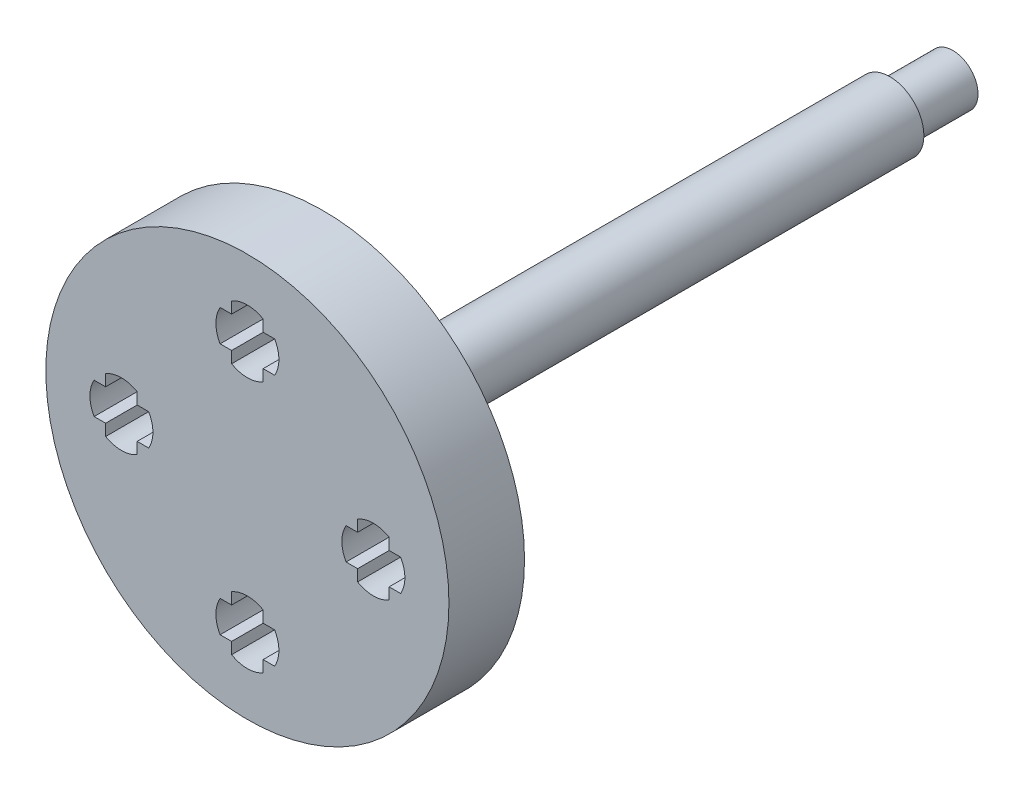
from build123d import *

# Parameters (mm, degrees)
CROQUIS2_R              = 16
SALIENTE_EXTRUIR1_DEPTH = 6
CROQUIS3_R              = 2.7
SALIENTE_EXTRUIR2_DEPTH = 50
CROQUIS4_R              = 2.7
CROQUIS4_R_2            = 2
CORTAR_EXTRUIR1_DEPTH   = 5


with BuildPart() as part:
    # Croquis2 → Saliente-Extruir1 (new body)
    with BuildSketch(Plane.XY):
        Circle(CROQUIS2_R)
        with BuildLine():
            Line((1.25, 12.165063509), (1.25, 11.25))
            Line((1.25, 11.25), (2.165063509, 11.25))
            ThreePointArc((2.165063509, 11.25), (2.414814566, 10.647047613), (2.5, 10))
            ThreePointArc((2.5, 10), (2.414814566, 9.352952387), (2.165063509, 8.75))
            Line((2.165063509, 8.75), (1.25, 8.75))
            Line((1.25, 8.75), (1.25, 7.834936491))
            ThreePointArc((1.25, 7.834936491), (0.647047613, 7.585185434), (0, 7.5))
            ThreePointArc((0, 7.5), (-0.647047613, 7.585185434), (-1.25, 7.834936491))
            Line((-1.25, 7.834936491), (-1.25, 8.75))
            Line((-1.25, 8.75), (-2.165063509, 8.75))
            ThreePointArc((-2.165063509, 8.75), (-2.414814566, 9.352952387), (-2.5, 10))
            ThreePointArc((-2.5, 10), (-2.414814566, 10.647047613), (-2.165063509, 11.25))
            Line((-2.165063509, 11.25), (-1.25, 11.25))
            Line((-1.25, 11.25), (-1.25, 12.165063509))
            ThreePointArc((-1.25, 12.165063509), (-0.647047613, 12.414814566), (0, 12.5))
            ThreePointArc((0, 12.5), (0.647047613, 12.414814566), (1.25, 12.165063509))
        make_face(mode=Mode.SUBTRACT)
        with BuildLine():
            Line((12.165063509, -1.25), (11.25, -1.25))
            Line((11.25, -1.25), (11.25, -2.165063509))
            ThreePointArc((11.25, -2.165063509), (10.647047613, -2.414814566), (10, -2.5))
            ThreePointArc((10, -2.5), (9.352952387, -2.414814566), (8.75, -2.165063509))
            Line((8.75, -2.165063509), (8.75, -1.25))
            Line((8.75, -1.25), (7.834936491, -1.25))
            ThreePointArc((7.834936491, -1.25), (7.585185434, -0.647047613), (7.5, 0))
            ThreePointArc((7.5, 0), (7.585185434, 0.647047613), (7.834936491, 1.25))
            Line((7.834936491, 1.25), (8.75, 1.25))
            Line((8.75, 1.25), (8.75, 2.165063509))
            ThreePointArc((8.75, 2.165063509), (9.352952387, 2.414814566), (10, 2.5))
            ThreePointArc((10, 2.5), (10.647047613, 2.414814566), (11.25, 2.165063509))
            Line((11.25, 2.165063509), (11.25, 1.25))
            Line((11.25, 1.25), (12.165063509, 1.25))
            ThreePointArc((12.165063509, 1.25), (12.414814566, 0.647047613), (12.5, 0))
            ThreePointArc((12.5, 0), (12.414814566, -0.647047613), (12.165063509, -1.25))
        make_face(mode=Mode.SUBTRACT)
        with BuildLine():
            Line((-1.25, -12.165063509), (-1.25, -11.25))
            Line((-1.25, -11.25), (-2.165063509, -11.25))
            ThreePointArc((-2.165063509, -11.25), (-2.414814566, -10.647047613), (-2.5, -10))
            ThreePointArc((-2.5, -10), (-2.414814566, -9.352952387), (-2.165063509, -8.75))
            Line((-2.165063509, -8.75), (-1.25, -8.75))
            Line((-1.25, -8.75), (-1.25, -7.834936491))
            ThreePointArc((-1.25, -7.834936491), (-0.647047613, -7.585185434), (0, -7.5))
            ThreePointArc((0, -7.5), (0.647047613, -7.585185434), (1.25, -7.834936491))
            Line((1.25, -7.834936491), (1.25, -8.75))
            Line((1.25, -8.75), (2.165063509, -8.75))
            ThreePointArc((2.165063509, -8.75), (2.414814566, -9.352952387), (2.5, -10))
            ThreePointArc((2.5, -10), (2.414814566, -10.647047613), (2.165063509, -11.25))
            Line((2.165063509, -11.25), (1.25, -11.25))
            Line((1.25, -11.25), (1.25, -12.165063509))
            ThreePointArc((1.25, -12.165063509), (0.647047613, -12.414814566), (0, -12.5))
            ThreePointArc((0, -12.5), (-0.647047613, -12.414814566), (-1.25, -12.165063509))
        make_face(mode=Mode.SUBTRACT)
        with BuildLine():
            Line((-12.165063509, 1.25), (-11.25, 1.25))
            Line((-11.25, 1.25), (-11.25, 2.165063509))
            ThreePointArc((-11.25, 2.165063509), (-10.647047613, 2.414814566), (-10, 2.5))
            ThreePointArc((-10, 2.5), (-9.352952387, 2.414814566), (-8.75, 2.165063509))
            Line((-8.75, 2.165063509), (-8.75, 1.25))
            Line((-8.75, 1.25), (-7.834936491, 1.25))
            ThreePointArc((-7.834936491, 1.25), (-7.585185434, 0.647047613), (-7.5, 0))
            ThreePointArc((-7.5, 0), (-7.585185434, -0.647047613), (-7.834936491, -1.25))
            Line((-7.834936491, -1.25), (-8.75, -1.25))
            Line((-8.75, -1.25), (-8.75, -2.165063509))
            ThreePointArc((-8.75, -2.165063509), (-9.352952387, -2.414814566), (-10, -2.5))
            ThreePointArc((-10, -2.5), (-10.647047613, -2.414814566), (-11.25, -2.165063509))
            Line((-11.25, -2.165063509), (-11.25, -1.25))
            Line((-11.25, -1.25), (-12.165063509, -1.25))
            ThreePointArc((-12.165063509, -1.25), (-12.414814566, -0.647047613), (-12.5, 0))
            ThreePointArc((-12.5, 0), (-12.414814566, 0.647047613), (-12.165063509, 1.25))
        make_face(mode=Mode.SUBTRACT)
    extrude(amount=SALIENTE_EXTRUIR1_DEPTH)

    # Croquis3 → Saliente-Extruir2 (add)
    with BuildSketch(Plane(origin=(0, 0, 0), x_dir=(-1, 0, 0), z_dir=(0, 0, -1))):
        Circle(CROQUIS3_R)
    extrude(amount=SALIENTE_EXTRUIR2_DEPTH)

    # Croquis4 → Cortar-Extruir1 (cut)
    with BuildSketch(Plane(origin=(0, 0, -50), x_dir=(-1, 0, 0), z_dir=(0, 0, -1))):
        Circle(CROQUIS4_R)
        Circle(CROQUIS4_R_2, mode=Mode.SUBTRACT)
    extrude(amount=-CORTAR_EXTRUIR1_DEPTH, mode=Mode.SUBTRACT)


solid = part.part
